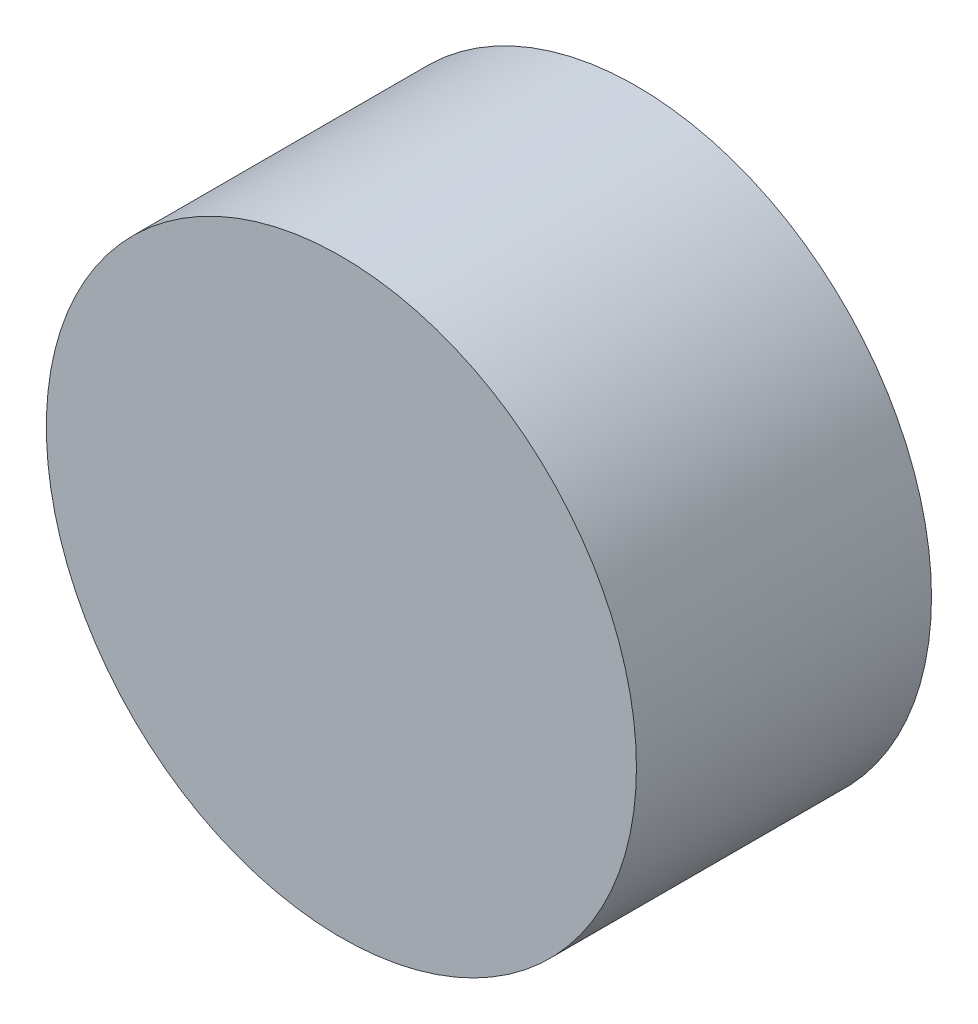
from build123d import *

# Parameters (mm, degrees)
SKETCH1_R           = 101.6
BOSS_EXTRUDE1_DEPTH = 101.6


with BuildPart() as part:
    # Sketch1 → Boss-Extrude1 (new body)
    with BuildSketch(Plane.XY):
        Circle(SKETCH1_R)
    extrude(amount=-BOSS_EXTRUDE1_DEPTH)


solid = part.part
